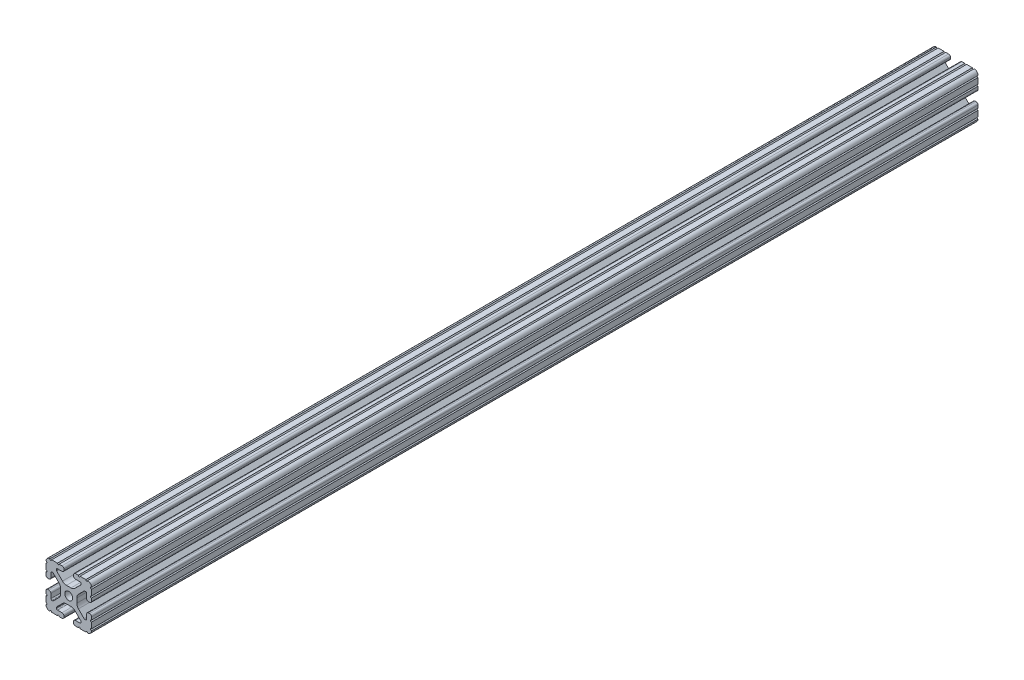
from build123d import *

# Parameters (mm, degrees)
SKETCH3_R                = 3.3274
BOSS_EXTRUDE1_DEPTH      = 457.2
BOSS_EXTRUDE1_DEPTH_BACK = 457.2
CUT_EXTRUDE1_DEPTH       = 22.86


with BuildPart() as part:
    # Sketch3 → Boss-Extrude1 (new body, two sides)
    with BuildSketch(Plane.XY) as boss_extrude1_sk:
        with BuildLine():
            Line((-4.064, 16.539617549), (-4.064, 17.496382451))
            ThreePointArc((-4.064, 17.496382451), (-4.519044045, 18.594955955), (-5.617617549, 19.05))
            Line((-5.617617549, 19.05), (-7.974178704, 19.05))
            ThreePointArc((-7.974178704, 19.05), (-8.736178704, 18.288), (-9.498178704, 19.05))
            Line((-9.498178704, 19.05), (-14.327719207, 19.05))
            ThreePointArc((-14.327719207, 19.05), (-15.087603123, 18.231251131), (-15.847487039, 19.05))
            ThreePointArc((-15.847487039, 19.05), (-18.120176289, 18.120192083), (-19.05, 15.847509295))
            ThreePointArc((-19.05, 15.847509295), (-18.231250992, 15.08762539), (-19.05, 14.327741484))
            Line((-19.05, 14.327741484), (-19.05, 9.496091471))
            ThreePointArc((-19.05, 9.496091471), (-18.231250992, 8.736207565), (-19.05, 7.97632366))
            Line((-19.05, 7.97632366), (-19.05, 5.617617549))
            ThreePointArc((-19.05, 5.617617549), (-18.594955955, 4.519044045), (-17.496382451, 4.064))
            Line((-17.496382451, 4.064), (-16.539617549, 4.064))
            ThreePointArc((-16.539617549, 4.064), (-15.441044045, 4.519044045), (-14.986, 5.617617549))
            Line((-14.986, 5.617617549), (-14.986, 9.385342516))
            ThreePointArc((-14.986, 9.385342516), (-14.721898185, 10.022940701), (-14.0843, 10.287042516))
            Line((-14.0843, 10.287042516), (-13.516042086, 10.287042516))
            ThreePointArc((-13.516042086, 10.287042516), (-13.170975923, 10.218404478), (-12.878443117, 10.022939917))
            Line((-12.878443117, 10.022939917), (-8.14758008, 5.292065243))
            ThreePointArc((-8.14758008, 5.292065243), (-7.117955879, 3.751120653), (-6.7564, 1.933453584))
            Line((-6.7564, 1.933453584), (-6.7564, -1.933453584))
            ThreePointArc((-6.7564, -1.933453584), (-7.117955879, -3.751120653), (-8.14758008, -5.292065243))
            Line((-8.14758008, -5.292065243), (-12.878443117, -10.022939917))
            ThreePointArc((-12.878443117, -10.022939917), (-13.170975923, -10.218404478), (-13.516042086, -10.287042516))
            Line((-13.516042086, -10.287042516), (-14.0843, -10.287042516))
            ThreePointArc((-14.0843, -10.287042516), (-14.721898185, -10.022940701), (-14.986, -9.385342516))
            Line((-14.986, -9.385342516), (-14.986, -5.617617549))
            ThreePointArc((-14.986, -5.617617549), (-15.441044045, -4.519044045), (-16.539617549, -4.064))
            Line((-16.539617549, -4.064), (-17.496382451, -4.064))
            ThreePointArc((-17.496382451, -4.064), (-18.594955955, -4.519044045), (-19.05, -5.617617549))
            Line((-19.05, -5.617617549), (-19.05, -7.976318491))
            ThreePointArc((-19.05, -7.976318491), (-18.231250992, -8.736202396), (-19.05, -9.496086302))
            Line((-19.05, -9.496086302), (-19.05, -14.32774291))
            ThreePointArc((-19.05, -14.32774291), (-18.231250992, -15.087626816), (-19.05, -15.847510721))
            ThreePointArc((-19.05, -15.847510721), (-18.120175716, -18.120192644), (-15.847486868, -19.05))
            ThreePointArc((-15.847486868, -19.05), (-15.087602952, -18.231251131), (-14.327719036, -19.05))
            Line((-14.327719036, -19.05), (-9.496062448, -19.05))
            ThreePointArc((-9.496062448, -19.05), (-8.736178532, -18.231251131), (-7.976294616, -19.05))
            Line((-7.976294616, -19.05), (-5.617617549, -19.05))
            ThreePointArc((-5.617617549, -19.05), (-4.519044045, -18.594955955), (-4.064, -17.496382451))
            Line((-4.064, -17.496382451), (-4.064, -16.539617549))
            ThreePointArc((-4.064, -16.539617549), (-4.519044045, -15.441044045), (-5.617617549, -14.986))
            Line((-5.617617549, -14.986), (-9.3853, -14.986))
            ThreePointArc((-9.3853, -14.986), (-10.022898185, -14.721898185), (-10.287, -14.0843))
            Line((-10.287, -14.0843), (-10.287, -13.552357131))
            ThreePointArc((-10.287, -13.552357131), (-10.218362387, -13.207291992), (-10.022898969, -12.91475973))
            Line((-10.022898969, -12.91475973), (-5.252158105, -8.144007132))
            ThreePointArc((-5.252158105, -8.144007132), (-3.715177372, -7.117027388), (-1.902183975, -6.7564))
            Line((-1.902183975, -6.7564), (1.902183975, -6.7564))
            ThreePointArc((1.902183975, -6.7564), (3.715177372, -7.117027388), (5.252158105, -8.144007132))
            Line((5.252158105, -8.144007132), (10.022898969, -12.91475973))
            ThreePointArc((10.022898969, -12.91475973), (10.218362387, -13.207291992), (10.287, -13.552357131))
            Line((10.287, -13.552357131), (10.287, -14.0843))
            ThreePointArc((10.287, -14.0843), (10.022898185, -14.721898185), (9.3853, -14.986))
            Line((9.3853, -14.986), (5.617617549, -14.986))
            ThreePointArc((5.617617549, -14.986), (4.519044045, -15.441044045), (4.064, -16.539617549))
            Line((4.064, -16.539617549), (4.064, -17.496382451))
            ThreePointArc((4.064, -17.496382451), (4.519044045, -18.594955955), (5.617617549, -19.05))
            Line((5.617617549, -19.05), (7.976294616, -19.05))
            ThreePointArc((7.976294616, -19.05), (8.736178532, -18.231251131), (9.496062448, -19.05))
            Line((9.496062448, -19.05), (14.327719036, -19.05))
            ThreePointArc((14.327719036, -19.05), (15.087602952, -18.231251131), (15.847486868, -19.05))
            ThreePointArc((15.847486868, -19.05), (18.120175716, -18.120192644), (19.05, -15.847510721))
            ThreePointArc((19.05, -15.847510721), (18.231250992, -15.087626816), (19.05, -14.32774291))
            Line((19.05, -14.32774291), (19.05, -9.496086302))
            ThreePointArc((19.05, -9.496086302), (18.231250992, -8.736202396), (19.05, -7.976318491))
            Line((19.05, -7.976318491), (19.05, -5.617617549))
            ThreePointArc((19.05, -5.617617549), (18.594955955, -4.519044045), (17.496382451, -4.064))
            Line((17.496382451, -4.064), (16.539617549, -4.064))
            ThreePointArc((16.539617549, -4.064), (15.441044045, -4.519044045), (14.986, -5.617617549))
            Line((14.986, -5.617617549), (14.986, -9.385342516))
            ThreePointArc((14.986, -9.385342516), (14.721898185, -10.022940701), (14.0843, -10.287042516))
            Line((14.0843, -10.287042516), (13.516042086, -10.287042516))
            ThreePointArc((13.516042086, -10.287042516), (13.170975923, -10.218404478), (12.878443117, -10.022939917))
            Line((12.878443117, -10.022939917), (8.14758008, -5.292065243))
            ThreePointArc((8.14758008, -5.292065243), (7.117955879, -3.751120653), (6.7564, -1.933453584))
            Line((6.7564, -1.933453584), (6.7564, 1.933453584))
            ThreePointArc((6.7564, 1.933453584), (7.117955879, 3.751120653), (8.14758008, 5.292065243))
            Line((8.14758008, 5.292065243), (12.878443117, 10.022939917))
            ThreePointArc((12.878443117, 10.022939917), (13.170975923, 10.218404478), (13.516042086, 10.287042516))
            Line((13.516042086, 10.287042516), (14.0843, 10.287042516))
            ThreePointArc((14.0843, 10.287042516), (14.721898185, 10.022940701), (14.986, 9.385342516))
            Line((14.986, 9.385342516), (14.986, 5.617617549))
            ThreePointArc((14.986, 5.617617549), (15.441044045, 4.519044045), (16.539617549, 4.064))
            Line((16.539617549, 4.064), (17.496382451, 4.064))
            ThreePointArc((17.496382451, 4.064), (18.594955955, 4.519044045), (19.05, 5.617617549))
            Line((19.05, 5.617617549), (19.05, 7.97632366))
            ThreePointArc((19.05, 7.97632366), (18.231250992, 8.736207565), (19.05, 9.496091471))
            Line((19.05, 9.496091471), (19.05, 14.327741484))
            ThreePointArc((19.05, 14.327741484), (18.231250992, 15.08762539), (19.05, 15.847509295))
            ThreePointArc((19.05, 15.847509295), (18.120176289, 18.120192083), (15.847487039, 19.05))
            ThreePointArc((15.847487039, 19.05), (15.087603123, 18.231251131), (14.327719207, 19.05))
            Line((14.327719207, 19.05), (9.498178704, 19.05))
            ThreePointArc((9.498178704, 19.05), (8.736178704, 18.288), (7.974178704, 19.05))
            Line((7.974178704, 19.05), (5.617617549, 19.05))
            ThreePointArc((5.617617549, 19.05), (4.519044045, 18.594955955), (4.064, 17.496382451))
            Line((4.064, 17.496382451), (4.064, 16.539617549))
            ThreePointArc((4.064, 16.539617549), (4.519044045, 15.441044045), (5.617617549, 14.986))
            Line((5.617617549, 14.986), (9.3853, 14.986))
            ThreePointArc((9.3853, 14.986), (10.022898185, 14.721898185), (10.287, 14.0843))
            Line((10.287, 14.0843), (10.287, 13.552357131))
            ThreePointArc((10.287, 13.552357131), (10.218362387, 13.207291992), (10.022898969, 12.91475973))
            Line((10.022898969, 12.91475973), (5.252158105, 8.144007132))
            ThreePointArc((5.252158105, 8.144007132), (3.715177372, 7.117027388), (1.902183975, 6.7564))
            Line((1.902183975, 6.7564), (-1.902183975, 6.7564))
            ThreePointArc((-1.902183975, 6.7564), (-3.715177372, 7.117027388), (-5.252158105, 8.144007132))
            Line((-5.252158105, 8.144007132), (-10.022898969, 12.91475973))
            ThreePointArc((-10.022898969, 12.91475973), (-10.218362387, 13.207291992), (-10.287, 13.552357131))
            Line((-10.287, 13.552357131), (-10.287, 14.0843))
            ThreePointArc((-10.287, 14.0843), (-10.022898185, 14.721898185), (-9.3853, 14.986))
            Line((-9.3853, 14.986), (-5.617617549, 14.986))
            ThreePointArc((-5.617617549, 14.986), (-4.519044045, 15.441044045), (-4.064, 16.539617549))
        make_face()
        Circle(SKETCH3_R, mode=Mode.SUBTRACT)
    extrude(amount=BOSS_EXTRUDE1_DEPTH)
    extrude(boss_extrude1_sk.sketch, amount=-BOSS_EXTRUDE1_DEPTH_BACK)

    # Sketch4 → Cut-Extrude1 (cut, symmetric)
    with BuildSketch(Plane(origin=(0, 0, 0), x_dir=(1, 0, 0), z_dir=(0, 1, 0))):
        Polygon((-11.912948955, -285.75), (-26.025980117, -285.75), (-26.025980117, -467.527100799), (32.635256624, -467.527100799), (32.635256624, -285.75), align=None)
    extrude(amount=CUT_EXTRUDE1_DEPTH, both=True, mode=Mode.SUBTRACT)


solid = part.part
